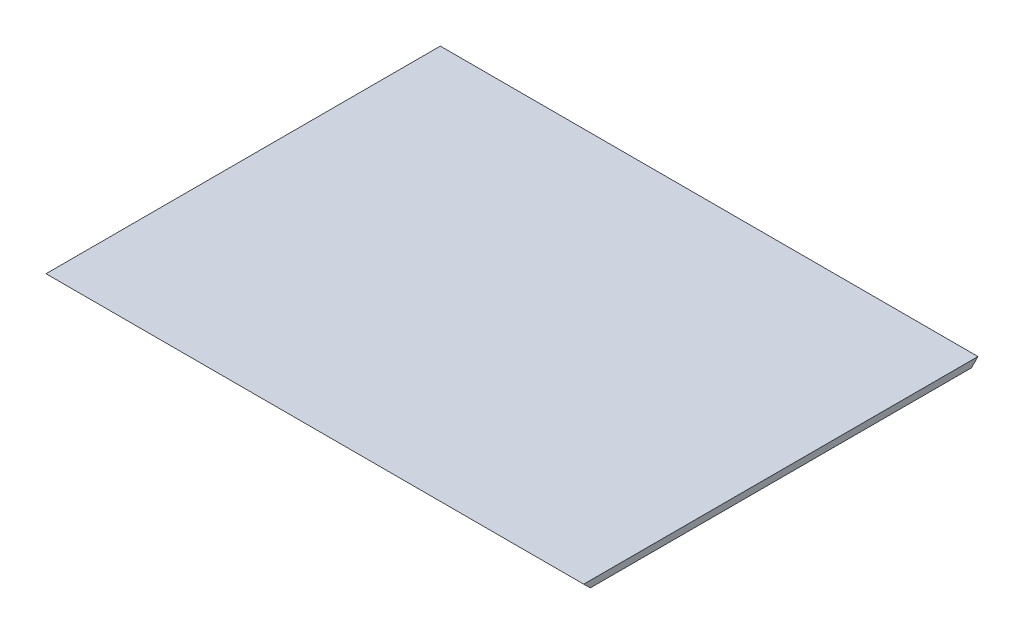
from build123d import *

# Parameters (mm, degrees)
SKETCH1_W           = 260.35
SKETCH1_H           = 241.046
BOSS_EXTRUDE1_DEPTH = 1.5875
CUT_EXTRUDE2_DEPTH  = 261.35
CUT_EXTRUDE3_DEPTH  = 261.35


with BuildPart() as part:
    # Sketch1 → Boss-Extrude1 (new body, symmetric)
    with BuildSketch(Plane(origin=(0, 0, 0), x_dir=(1, 0, 0), z_dir=(0, 1, 0))):
        Rectangle(SKETCH1_W, SKETCH1_H)
    extrude(amount=BOSS_EXTRUDE1_DEPTH, both=True)

    # Sketch3 → Cut-Extrude2 (cut, through all)
    with BuildSketch(Plane.ZY.offset(130.175)):
        Polygon((120.523, 1.5875), (117.316753604, -1.5875), (181.759591699, -66.664544845), (184.965838095, -63.489544845), align=None)
        Polygon((-120.523, 1.5875), (-115.936493069, -2.999006931), (-117.69089956, -4.753413422), (-122.277406491, -0.166906491), align=None)
    extrude(amount=-CUT_EXTRUDE2_DEPTH, mode=Mode.SUBTRACT)

    # Sketch4 → Cut-Extrude3 (cut, through all)
    with BuildSketch(Plane.ZY.offset(130.175)):
        Polygon((-95.828811288, 27.019066154), (-49.030213399, -19.779531735), (-139.395977622, -13.401975952), align=None)
    extrude(amount=-CUT_EXTRUDE3_DEPTH, mode=Mode.SUBTRACT)


solid = part.part
